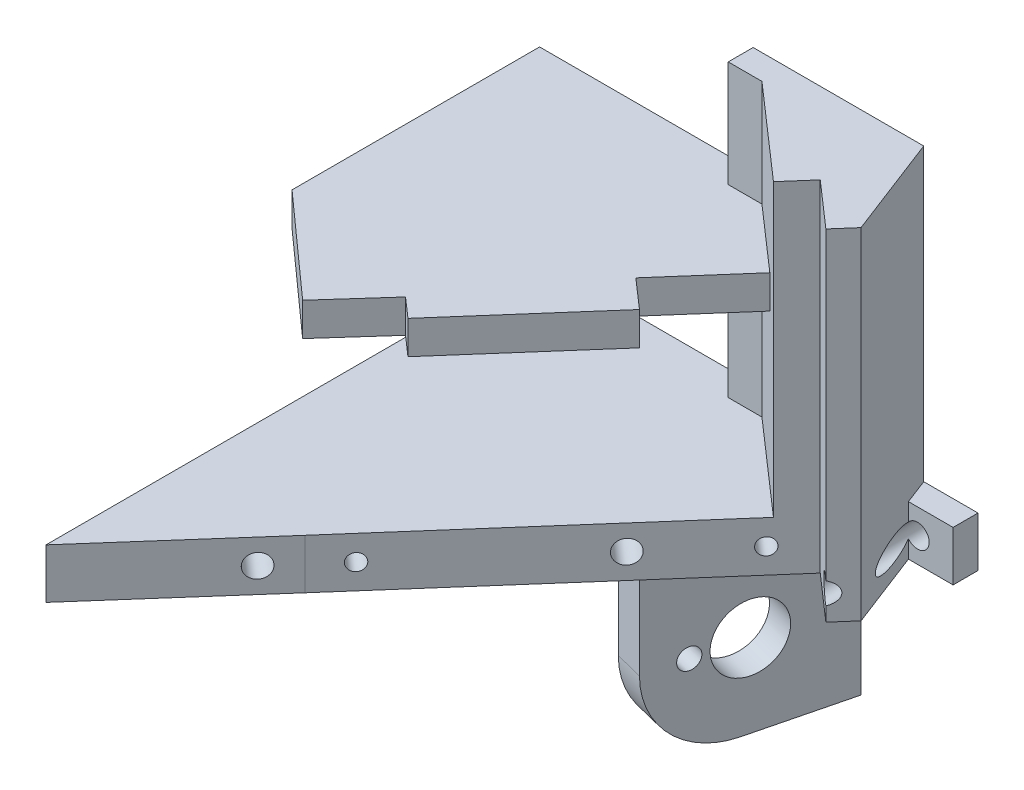
from build123d import *

# Parameters (mm, degrees)
ESQUISSE4_W             = 52.781616476
ESQUISSE4_H             = 6
BOSS_EXTRU_1_DEPTH      = 3
BOSS_EXTRU_2_DEPTH      = 41
ENL_V_MAT_EXTRU_1_DEPTH = 35
BOSS_EXTRU_3_DEPTH      = 4
ESQUISSE11_R            = 1.4
ENL_V_MAT_EXTRU_2_DEPTH = 43
BOSS_EXTRU_4_DEPTH      = 41
ESQUISSE15_R            = 1
ENL_V_MAT_EXTRU_4_DEPTH = 30
BOSS_EXTRU_5_DEPTH      = 20
ESQUISSE18_R            = 4
ENL_V_MAT_EXTRU_5_DEPTH = 12
ESQUISSE12_R            = 1.4
ENL_V_MAT_EXTRU_6_DEPTH = 18
ESQUISSE19_R            = 1.254640732
ENL_V_MAT_EXTRU_7_DEPTH = 18
CONG_1_R                = 10
ESQUISSE20_W            = 12.811790935
ESQUISSE20_H            = 3
BOSS_EXTRU_7_DEPTH      = 36


with BuildPart() as part:
    # Esquisse4 → Boss.-Extru.1 (new body)
    with BuildSketch(Plane.XY):
        with Locations((48.08341362, -51.85)):
            Rectangle(ESQUISSE4_W, ESQUISSE4_H)
    extrude(amount=BOSS_EXTRU_1_DEPTH)

    # Esquisse6 → Boss.-Extru.2 (add)
    with BuildSketch(Plane.XZ.offset(54.85)):
        Polygon((65.242227071, 9.760964304), (70.700086364, 14.539666718), (72.676320449, 12.282567065), (62.07450001, 3), (21.692605382, 3), (21.692605382, 29.804497378), (21.692605382, 59.423332345), (36.271065294, 42.849554228), align=None)
    extrude(amount=-BOSS_EXTRU_2_DEPTH)

    # Esquisse9 → Enlèv. mat.-Extru.1 (cut)
    with BuildSketch(Plane(origin=(0, -13.85, 0), x_dir=(1, 0, 0), z_dir=(0, 1, 0))):
        Polygon((36.271065294, -42.849554228), (62.613078874, -12.763771276), (51.461664708, -3), (21.692605382, -3), (21.692605382, -29.804497378), (21.692605382, -59.423332345), align=None)
    extrude(amount=-ENL_V_MAT_EXTRU_1_DEPTH, mode=Mode.SUBTRACT)

    # Esquisse10 → Boss.-Extru.3 (add)
    with BuildSketch(Plane(origin=(0, -26.644686639, 0), x_dir=(1, 0, 0), z_dir=(0, 1, 0))):
        Polygon((42.072152074, -36.224007657), (39.690998774, -34.139156727), (33.841851451, -40.675851871), (21.692605382, -29.804497378), (21.692605382, 0), (48.035299878, 0), (59.09491831, -9.68339828), (51.563800233, -18.28485098), (55.081960797, -21.365223976), align=None)
    extrude(amount=-BOSS_EXTRU_3_DEPTH)

    # Esquisse11 → Enlèv. mat.-Extru.2 (cut)
    with BuildSketch(Plane(origin=(41.768421189, 0, 36.570905264), x_dir=(0.658744695, 0, -0.752366551), z_dir=(0.752366551, 0, 0.658744695))):
        with Locations((19.134147904, -51.85)):
            Circle(ESQUISSE11_R)
        with Locations((-12.365852096, -51.85)):
            Circle(ESQUISSE11_R)
    extrude(amount=-ENL_V_MAT_EXTRU_2_DEPTH, mode=Mode.SUBTRACT)

    # Esquisse13 → Boss.-Extru.4 (add)
    with BuildSketch(Plane.XZ.offset(54.85)):
        Polygon((70.700086364, 14.539666718), (60.213373733, 5.357883848), (60.213373733, 0), (67.941059656, 0), (72.676320449, 12.282567065), align=None)
    extrude(amount=-BOSS_EXTRU_4_DEPTH)

    # Esquisse15 → Enlèv. mat.-Extru.4 (cut)
    with BuildSketch(Plane(origin=(41.768421189, 0, 36.570905264), x_dir=(0.658744695, 0, -0.752366551), z_dir=(0.752366551, 0, 0.658744695))):
        with Locations((31.034147904, -51.85)):
            Circle(ESQUISSE15_R)
        with Locations((-3.965852096, -51.85)):
            Circle(ESQUISSE15_R)
    extrude(amount=-ENL_V_MAT_EXTRU_4_DEPTH, mode=Mode.SUBTRACT)

    # Esquisse16 → Boss.-Extru.5 (add)
    with BuildSketch(Plane(origin=(0, -54.85, 0), x_dir=(1, 0, 0), z_dir=(0, 1, 0))):
        Polygon((60.41759692, 0), (55.081960797, -21.365223976), (51.686250118, -20.517197455), (56.810104658, 0), align=None)
    extrude(amount=-BOSS_EXTRU_5_DEPTH)

    # Esquisse18 → Enlèv. mat.-Extru.5 (cut)
    with BuildSketch(Plane(origin=(56.870719104, 0, 14.202587508), x_dir=(0.242293292, 0, -0.970203051), z_dir=(0.970203051, 0, 0.242293292))):
        with Locations((3.628081272, -64.85)):
            Circle(ESQUISSE18_R)
    extrude(amount=-ENL_V_MAT_EXTRU_5_DEPTH, mode=Mode.SUBTRACT)

    # Esquisse12 → Enlèv. mat.-Extru.6 (cut)
    with BuildSketch(Plane(origin=(0, 0, 0), x_dir=(-1, 0, 0), z_dir=(0, 0, -1))):
        with Locations((-24.42996151, -51.85)):
            Circle(ESQUISSE12_R)
        with Locations((-43.52996151, -51.85)):
            Circle(ESQUISSE12_R)
        with Locations((-55.197893581, -51.85)):
            Circle(ESQUISSE12_R)
        with Locations((-70.197893581, -51.85)):
            Circle(ESQUISSE12_R)
    extrude(amount=-ENL_V_MAT_EXTRU_6_DEPTH, mode=Mode.SUBTRACT)

    # Esquisse19 → Enlèv. mat.-Extru.7 (cut)
    with BuildSketch(Plane(origin=(56.870719104, 0, 14.202587508), x_dir=(0.242293292, 0, -0.970203051), z_dir=(0.970203051, 0, 0.242293292))):
        with Locations((-2.43609109, -64.85)):
            Circle(ESQUISSE19_R)
    extrude(amount=-ENL_V_MAT_EXTRU_7_DEPTH, mode=Mode.SUBTRACT)

    # Congé1
    cong_1_edges = [part.edges().sort_by_distance(p)[0] for p in [
        (53.384105458, -74.85, 20.941210715),
    ]]
    fillet(cong_1_edges, radius=CONG_1_R)

    # Esquisse20 → Boss.-Extru.7 (add)
    with BuildSketch(Plane(origin=(0, -13.85, 0), x_dir=(1, 0, 0), z_dir=(0, 1, 0))):
        with Locations((53.807478266, -1.5)):
            Rectangle(ESQUISSE20_W, ESQUISSE20_H)
    extrude(amount=-BOSS_EXTRU_7_DEPTH)


solid = part.part
